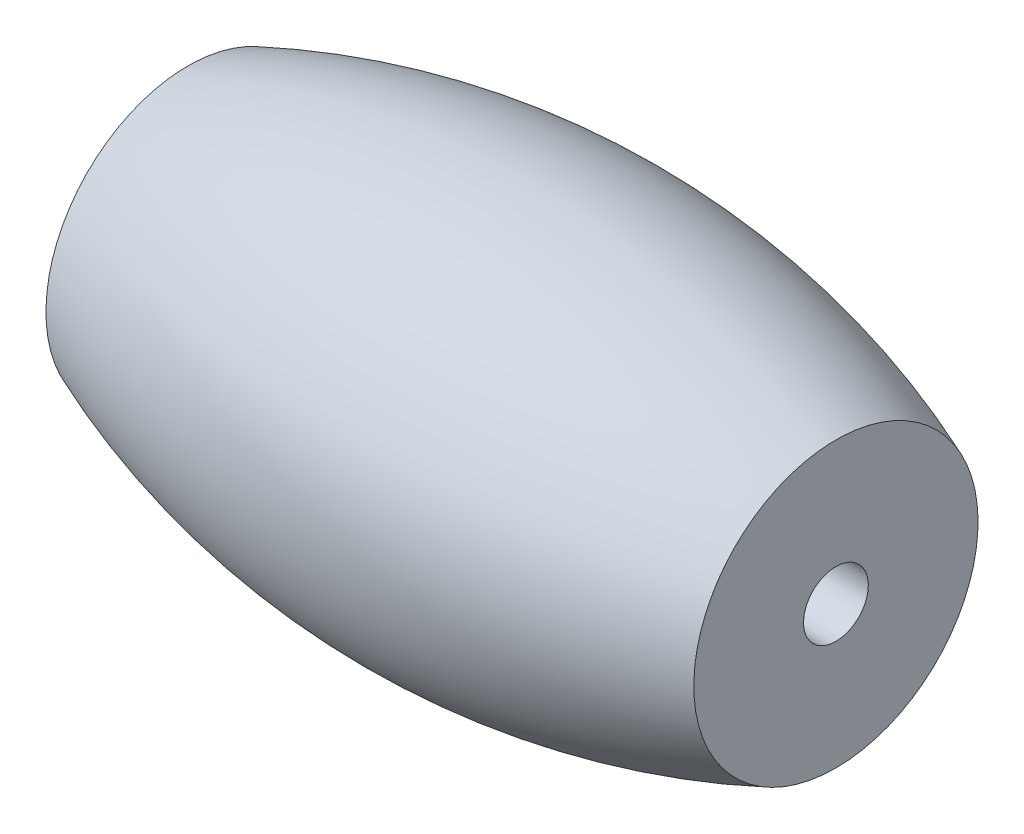
from build123d import *

# Parameters (mm, degrees)
ESBO_O2_R             = 1.5
CORTE_EXTRUS_O1_DEPTH = 31.0000001


with BuildPart() as part:
    # Esboço1 → Revolução2 (revolve)
    with BuildSketch(Plane.XY):
        with BuildLine():
            Line((-15, 30.5), (-15, 37.080992435))
            ThreePointArc((-15, 37.080992435), (0, 40), (15, 37.080992435))
            Line((15, 37.080992435), (15, 30.5))
            Line((15, 30.5), (-15, 30.5))
        make_face()
    revolve(axis=Axis((-15, 30.5, 0), (1, 0, 0)))

    # Esboço2 → Corte-extrusão1 (cut, through all)
    with BuildSketch(Plane.ZY.offset(15)):
        with Locations((0, 30.5)):
            Circle(ESBO_O2_R)
    extrude(amount=-CORTE_EXTRUS_O1_DEPTH, mode=Mode.SUBTRACT)


solid = part.part
